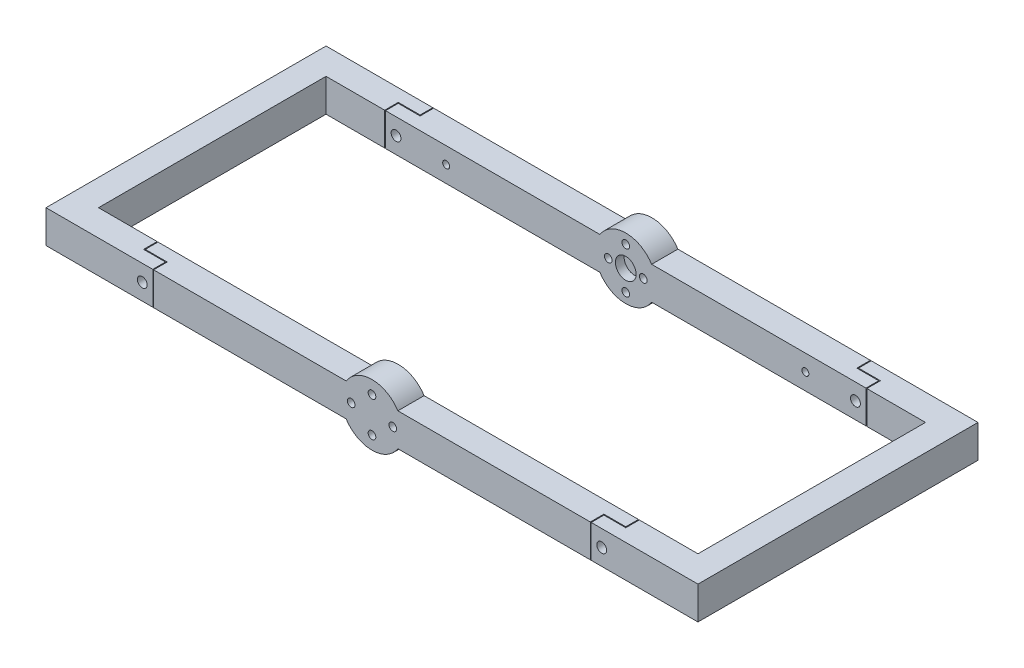
from build123d import *

# Parameters (mm, degrees)
SKETCH2_R           = 14
BOSS_EXTRUDE1_DEPTH = 12
SKETCH10_W          = 12
SKETCH10_H          = 15
BOSS_EXTRUDE5_DEPTH = 149
SKETCH11_W          = 12
SKETCH11_H          = 15
BOSS_EXTRUDE6_DEPTH = 104
SKETCH12_W          = 12
SKETCH12_H          = 15
BOSS_EXTRUDE7_DEPTH = 149
SKETCH13_R          = 14
BOSS_EXTRUDE8_DEPTH = 12
SKETCH4_R           = 4.75
CUT_EXTRUDE2_DEPTH  = 4
SKETCH3_R           = 1.75
CUT_EXTRUDE1_DEPTH  = 13
SKETCH14_R          = 4.75
CUT_EXTRUDE3_DEPTH  = 4
SKETCH15_R          = 1.75
CUT_EXTRUDE4_DEPTH  = 13
CUT_EXTRUDE5_DEPTH  = 22.5
SKETCH17_R          = 2.25
CUT_EXTRUDE6_DEPTH  = 129
SKETCH18_R          = 1.6
CUT_EXTRUDE7_DEPTH  = 12


with BuildPart() as part:
    # Sketch2 → Boss-Extrude1 (new body)
    with BuildSketch(Plane(origin=(0, 0, 12), x_dir=(-1, 0, 0), z_dir=(0, 0, -1))):
        Circle(SKETCH2_R)
    extrude(amount=BOSS_EXTRUDE1_DEPTH)

    # Sketch10 → Boss-Extrude5 (add)
    with BuildSketch(Plane(origin=(0, 0, 0), x_dir=(0, 0, -1), z_dir=(1, 0, 0))):
        with Locations((-6, 0)):
            Rectangle(SKETCH10_W, SKETCH10_H)
    boss_extrude5 = extrude(amount=BOSS_EXTRUDE5_DEPTH)

    # Sketch11 → Boss-Extrude6 (add)
    with BuildSketch(Plane.XY.offset(12)):
        with Locations((143, 0)):
            Rectangle(SKETCH11_W, SKETCH11_H)
    boss_extrude6 = extrude(amount=BOSS_EXTRUDE6_DEPTH)

    # Sketch12 → Boss-Extrude7 (add)
    with BuildSketch(Plane(origin=(149, 0, 0), x_dir=(0, 0, -1), z_dir=(1, 0, 0))):
        with Locations((-122, 0)):
            Rectangle(SKETCH12_W, SKETCH12_H)
    boss_extrude7 = extrude(amount=-BOSS_EXTRUDE7_DEPTH)

    # Sketch13 → Boss-Extrude8 (add)
    with BuildSketch(Plane.XY.offset(116)):
        Circle(SKETCH13_R)
    extrude(amount=BOSS_EXTRUDE8_DEPTH)

    # Mirror6: Boss-Extrude5, Boss-Extrude6, Boss-Extrude7 across plane
    add(boss_extrude5.mirror(Plane(origin=(0, 0, 0), x_dir=(0, 0, 1), z_dir=(1, 0, 0))))
    add(boss_extrude6.mirror(Plane(origin=(0, 0, 0), x_dir=(0, 0, 1), z_dir=(1, 0, 0))))
    add(boss_extrude7.mirror(Plane(origin=(0, 0, 0), x_dir=(0, 0, 1), z_dir=(1, 0, 0))))

    # Sketch4 → Cut-Extrude2 (cut)
    with BuildSketch(Plane.XY.offset(12)):
        Circle(SKETCH4_R)
    extrude(amount=-CUT_EXTRUDE2_DEPTH, mode=Mode.SUBTRACT)

    # Sketch3 → Cut-Extrude1 (cut, through all)
    with BuildSketch(Plane.XY.offset(12)):
        with Locations((8, 0)):
            Circle(SKETCH3_R)
        with Locations((0, -9.5)):
            Circle(SKETCH3_R)
        with Locations((-8, 0)):
            Circle(SKETCH3_R)
        with Locations((0, 9.5)):
            Circle(SKETCH3_R)
    extrude(amount=-CUT_EXTRUDE1_DEPTH, mode=Mode.SUBTRACT)

    # Sketch14 → Cut-Extrude3 (cut)
    with BuildSketch(Plane(origin=(0, 0, 116), x_dir=(-1, 0, 0), z_dir=(0, 0, -1))):
        Circle(SKETCH14_R)
    extrude(amount=-CUT_EXTRUDE3_DEPTH, mode=Mode.SUBTRACT)

    # Sketch15 → Cut-Extrude4 (cut, through all)
    with BuildSketch(Plane(origin=(0, 0, 116), x_dir=(-1, 0, 0), z_dir=(0, 0, -1))):
        with Locations((-9.5, 0)):
            Circle(SKETCH15_R)
        with Locations((0, 8)):
            Circle(SKETCH15_R)
        with Locations((9.5, 0)):
            Circle(SKETCH15_R)
        with Locations((0, -8)):
            Circle(SKETCH15_R)
    extrude(amount=-CUT_EXTRUDE4_DEPTH, mode=Mode.SUBTRACT)

    # Sketch16 → Cut-Extrude5 (cut, through all)
    with BuildSketch(Plane(origin=(0, 7.5, 0), x_dir=(1, 0, 0), z_dir=(0, 1, 0))):
        Polygon((99.8, 0), (99.8, -6.2), (109.8, -6.2), (109.8, -12), (110.2, -12), (110.2, -5.8), (100.2, -5.8), (100.2, 0), align=None)
        Polygon((109.8, -116), (110.2, -116), (110.2, -122.2), (100.2, -122.2), (100.2, -128), (99.8, -128), (99.8, -121.8), (109.8, -121.8), align=None)
        Polygon((-99.8, -128), (-100.2, -128), (-100.2, -122.2), (-110.2, -122.2), (-110.2, -116), (-109.8, -116), (-109.8, -121.8), (-99.8, -121.8), align=None)
        Polygon((-109.8, -12), (-110.2, -12), (-110.2, -5.8), (-100.2, -5.8), (-100.2, 0), (-99.8, 0), (-99.8, -6.2), (-109.8, -6.2), align=None)
    extrude(amount=-CUT_EXTRUDE5_DEPTH, mode=Mode.SUBTRACT)

    # Sketch17 → Cut-Extrude6 (cut, through all)
    with BuildSketch(Plane(origin=(0, 0, 0), x_dir=(-1, 0, 0), z_dir=(0, 0, -1))):
        with Locations((-105, 0)):
            Circle(SKETCH17_R)
    cut_extrude6 = extrude(amount=-CUT_EXTRUDE6_DEPTH, mode=Mode.SUBTRACT)

    # Mirror7: Cut-Extrude6 across plane
    add(cut_extrude6.mirror(Plane(origin=(0, 0, 0), x_dir=(0, 0, 1), z_dir=(1, 0, 0))), mode=Mode.SUBTRACT)

    # Sketch18 → Cut-Extrude7 (cut)
    with BuildSketch(Plane(origin=(0, 0, 0), x_dir=(-1, 0, 0), z_dir=(0, 0, -1))):
        with Locations((82.085, 0)):
            Circle(SKETCH18_R)
        with Locations((-82.085, 0)):
            Circle(SKETCH18_R)
    extrude(amount=-CUT_EXTRUDE7_DEPTH, mode=Mode.SUBTRACT)


solid = part.part
